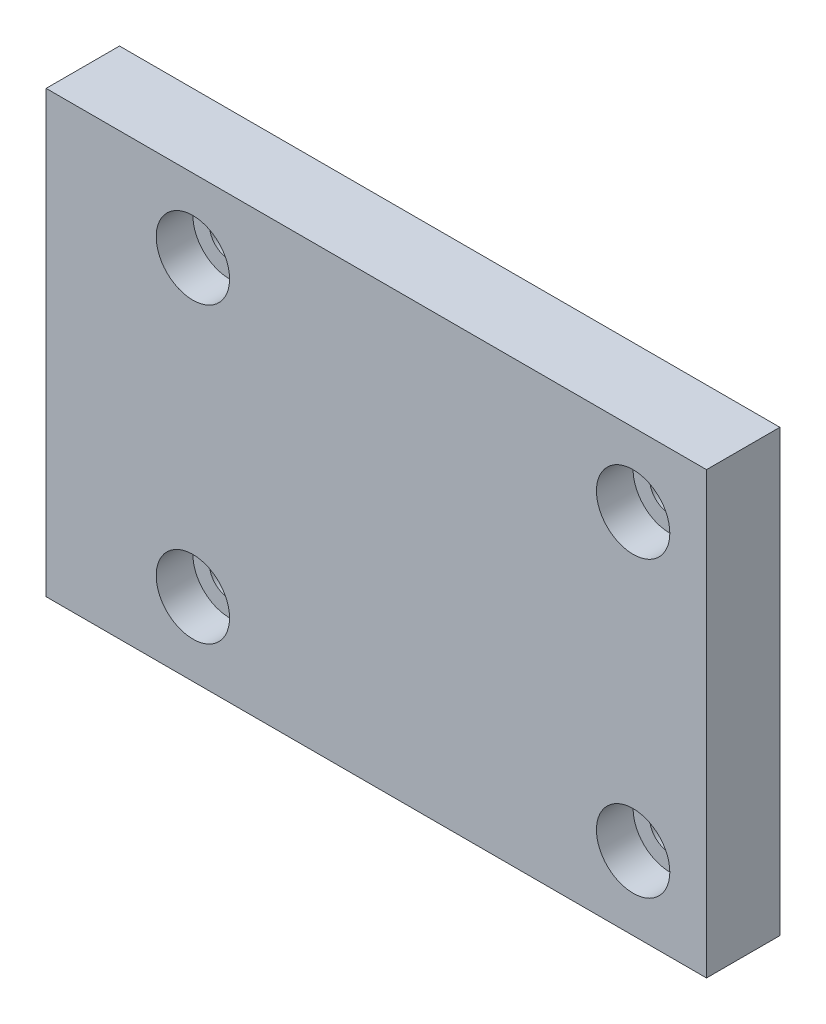
from build123d import *

# Parameters (mm, degrees)
SKETCH1_W                      = 90
SKETCH1_H                      = 60
BOSS_EXTRUDE1_DEPTH            = 5
CBORE_FOR_M5_SHCS1_D           = 5.5
CBORE_FOR_M5_SHCS1_CBORE_D     = 10
CBORE_FOR_M5_SHCS1_CBORE_DEPTH = 5
LPATTERN1_COUNT                = 2
LPATTERN1_PITCH                = 60
LPATTERN1_COUNT_DIR2           = 2
LPATTERN1_PITCH_DIR2           = 40


with BuildPart() as part:
    # Sketch1 → Boss-Extrude1 (new body, symmetric)
    with BuildSketch(Plane.XY):
        Rectangle(SKETCH1_W, SKETCH1_H)
    extrude(amount=BOSS_EXTRUDE1_DEPTH, both=True)

    # CBORE for M5 SHCS1 (through all)
    with Locations(Plane.XY.offset(5)):
        with Locations((-25, 20)):
            cbore_for_m5_shcs1 = CounterBoreHole(CBORE_FOR_M5_SHCS1_D / 2, CBORE_FOR_M5_SHCS1_CBORE_D / 2, CBORE_FOR_M5_SHCS1_CBORE_DEPTH)

    # LPattern1: CBORE for M5 SHCS1 2 × 2
    with Locations(*[(i * LPATTERN1_PITCH, -j * LPATTERN1_PITCH_DIR2, 0) for i in range(LPATTERN1_COUNT) for j in range(LPATTERN1_COUNT_DIR2) if (i, j) != (0, 0)]):
        add(cbore_for_m5_shcs1, mode=Mode.SUBTRACT)


solid = part.part
